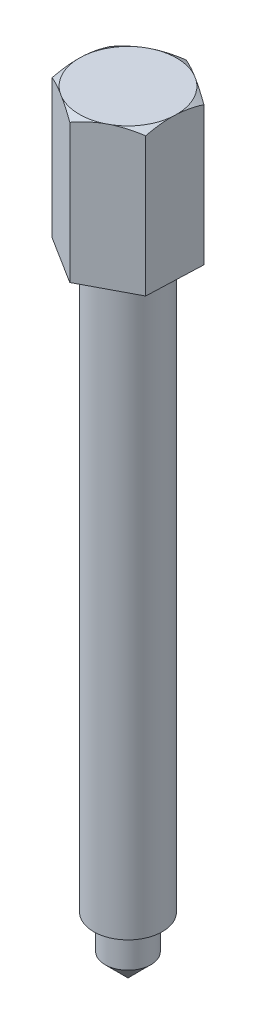
from build123d import *

# Parameters (mm, degrees)
SALIENTE_EXTRUIR1_DEPTH = 25


with BuildPart() as part:
    # Croquis1 → Revolución3 (revolve)
    with BuildSketch(Plane.XY):
        Polygon((0, 0), (0, -110), (4, -106), (4, -100), (6, -100), (6, 0), align=None)
    revolve(axis=Axis((0, 0, 0), (0, -1, 0)))

    # Croquis2 → Saliente-Extruir1 (add)
    with BuildSketch(Plane(origin=(0, 0, 0), x_dir=(1, 0, 0), z_dir=(0, 1, 0))):
        Polygon((8.310422033, -5.222089521), (8.677673202, 4.585991836), (0.367251169, 9.808081357), (-8.310422033, 5.222089521), (-8.677673202, -4.585991836), (-0.367251169, -9.808081357), align=None)
    extrude(amount=SALIENTE_EXTRUIR1_DEPTH)

    # Croquis3 → Cortar-Revolución1 (revolve, cut)
    with BuildSketch(Plane(origin=(0, 0, 0), x_dir=(0, 0, -1), z_dir=(1, 0, 0))):
        Polygon((5.04976064, 27.002153948), (10.24964381, 27.002153948), (10.24964381, 24), align=None)
    revolve(axis=Axis((0, 0, 0), (0, 1, 0)), mode=Mode.SUBTRACT)


solid = part.part
